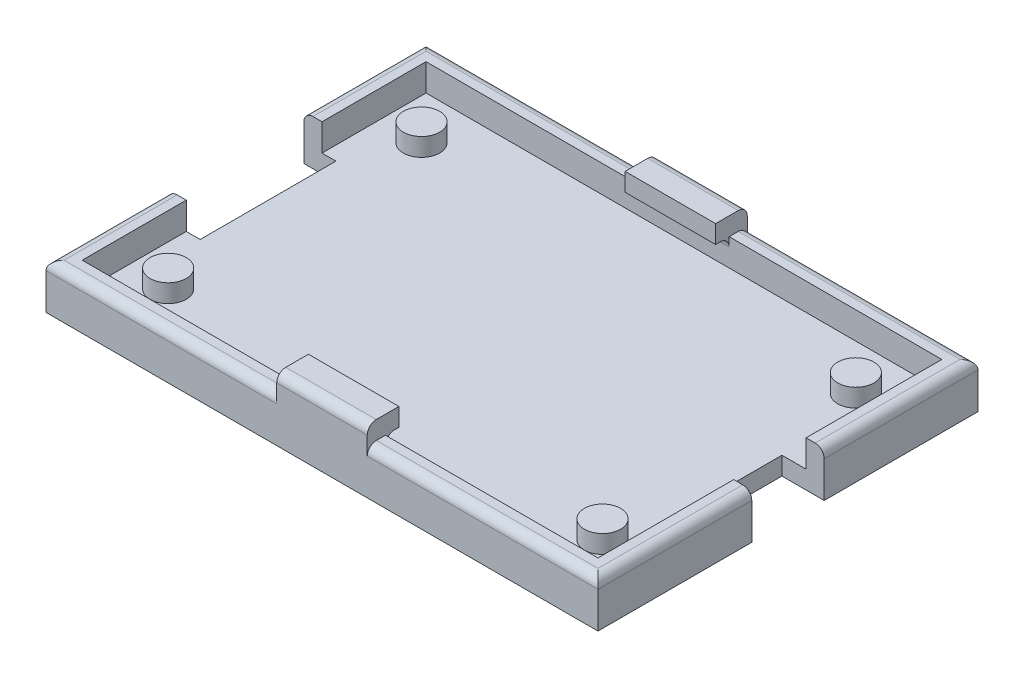
from build123d import *

# Parameters (mm, degrees)
SKETCH1_W           = 61
SKETCH1_H           = 42
BOSS_EXTRUDE1_DEPTH = 2
SKETCH2_W           = 61
SKETCH2_H           = 42
SKETCH2_W_2         = 57
SKETCH2_H_2         = 38
BOSS_EXTRUDE2_DEPTH = 3
SKETCH3_W           = 5.775270692
SKETCH3_H           = 15
SKETCH3_W_2         = 6.454719949
SKETCH3_H_2         = 8
CUT_EXTRUDE1_DEPTH  = 5
SKETCH4_R           = 2
BOSS_EXTRUDE3_DEPTH = 2
SKETCH5_W           = 10
SKETCH5_H           = 3.5
BOSS_EXTRUDE4_DEPTH = 2
FILLET1_R           = 1
FILLET2_R           = 1


with BuildPart() as part:
    # Sketch1 → Boss-Extrude1 (new body)
    with BuildSketch(Plane(origin=(0, 0, 0), x_dir=(1, 0, 0), z_dir=(0, 1, 0))):
        with Locations((9.74023618, -1.906412613)):
            Rectangle(SKETCH1_W, SKETCH1_H)
    extrude(amount=BOSS_EXTRUDE1_DEPTH)

    # Sketch2 → Boss-Extrude2 (add)
    with BuildSketch(Plane(origin=(0, 2, 0), x_dir=(1, 0, 0), z_dir=(0, 1, 0))):
        with Locations((9.74023618, -1.906412613)):
            Rectangle(SKETCH2_W, SKETCH2_H)
        with Locations((9.74023618, -1.906412613)):
            Rectangle(SKETCH2_W_2, SKETCH2_H_2, mode=Mode.SUBTRACT)
    extrude(amount=BOSS_EXTRUDE2_DEPTH)

    # Sketch3 → Cut-Extrude1 (cut)
    with BuildSketch(Plane(origin=(0, 5, 0), x_dir=(1, 0, 0), z_dir=(0, 1, 0))):
        with Locations((-20.110444063, -1.906412613)):
            Rectangle(SKETCH3_W, SKETCH3_H)
        with Locations((38.800224202, -1.906412613)):
            Rectangle(SKETCH3_W_2, SKETCH3_H_2)
    extrude(amount=-CUT_EXTRUDE1_DEPTH, mode=Mode.SUBTRACT)

    # Sketch4 → Boss-Extrude3 (add)
    with BuildSketch(Plane(origin=(0, 2, 0), x_dir=(1, 0, 0), z_dir=(0, 1, 0))):
        with Locations((-14.25976382, -15.906412613)):
            Circle(SKETCH4_R)
        with Locations((-14.25976382, 12.093587387)):
            Circle(SKETCH4_R)
        with Locations((33.74023618, 12.093587387)):
            Circle(SKETCH4_R)
        with Locations((33.74023618, -15.906412613)):
            Circle(SKETCH4_R)
    extrude(amount=BOSS_EXTRUDE3_DEPTH)

    # Sketch5 → Boss-Extrude4 (add)
    with BuildSketch(Plane(origin=(0, 5, 0), x_dir=(1, 0, 0), z_dir=(0, 1, 0))):
        with Locations((9.74023618, -21.156412613)):
            Rectangle(SKETCH5_W, SKETCH5_H)
        with Locations((9.74023618, 17.343587387)):
            Rectangle(SKETCH5_W, SKETCH5_H)
    extrude(amount=BOSS_EXTRUDE4_DEPTH)

    # Fillet1
    fillet1_edges = [part.edges().sort_by_distance(p)[0] for p in [
        (9.74023618, 5, 20.906412613),
        (9.74023618, 5, -17.093587387),
    ]]
    fillet(fillet1_edges, radius=FILLET1_R)

    # Fillet2
    fillet2_edges = [part.edges().sort_by_distance(p)[0] for p in [
        (27.49023618, 5, 22.906412613),
        (9.74023618, 7, 22.906412613),
        (-8.00976382, 5, -19.093587387),
        (9.74023618, 7, -19.093587387),
        (-20.75976382, 5, -12.343587387),
        (-8.00976382, 5, 22.906412613),
        (40.24023618, 5, 14.406412613),
        (27.49023618, 5, -19.093587387),
        (-20.75976382, 5, 16.156412613),
        (40.24023618, 5, -10.593587387),
    ]]
    fillet(fillet2_edges, radius=FILLET2_R)


solid = part.part
